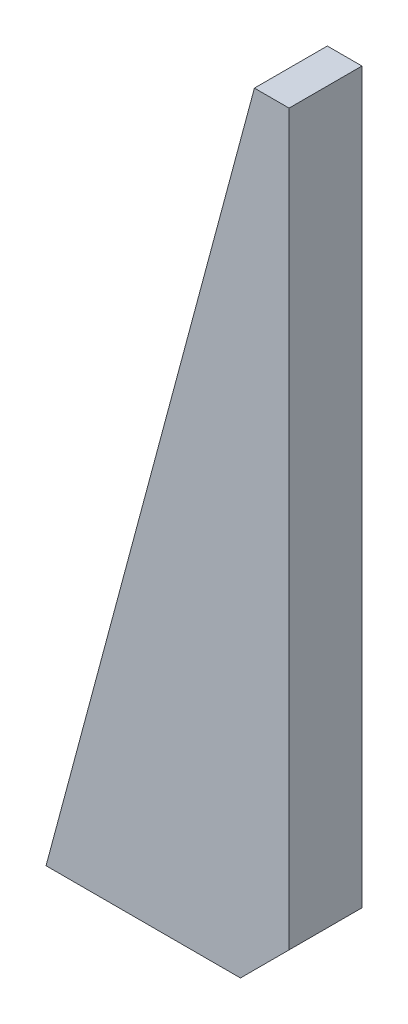
from build123d import *

# Parameters (mm, degrees)
BOSS_EXTRUDE1_DEPTH = 15
CHAMFER1_SIZE       = 10


with BuildPart() as part:
    # Sketch1 → Boss-Extrude1 (new body)
    with BuildSketch(Plane.XY):
        Polygon((0, 0), (-42.871870789, -160), (7.128129211, -160), (7.128129211, 0), align=None)
    extrude(amount=BOSS_EXTRUDE1_DEPTH)

    # Chamfer1
    chamfer1_edges = [part.edges().sort_by_distance(p)[0] for p in [
        (7.128129211, -160, 7.5),
    ]]
    chamfer(chamfer1_edges, length=CHAMFER1_SIZE)


solid = part.part
